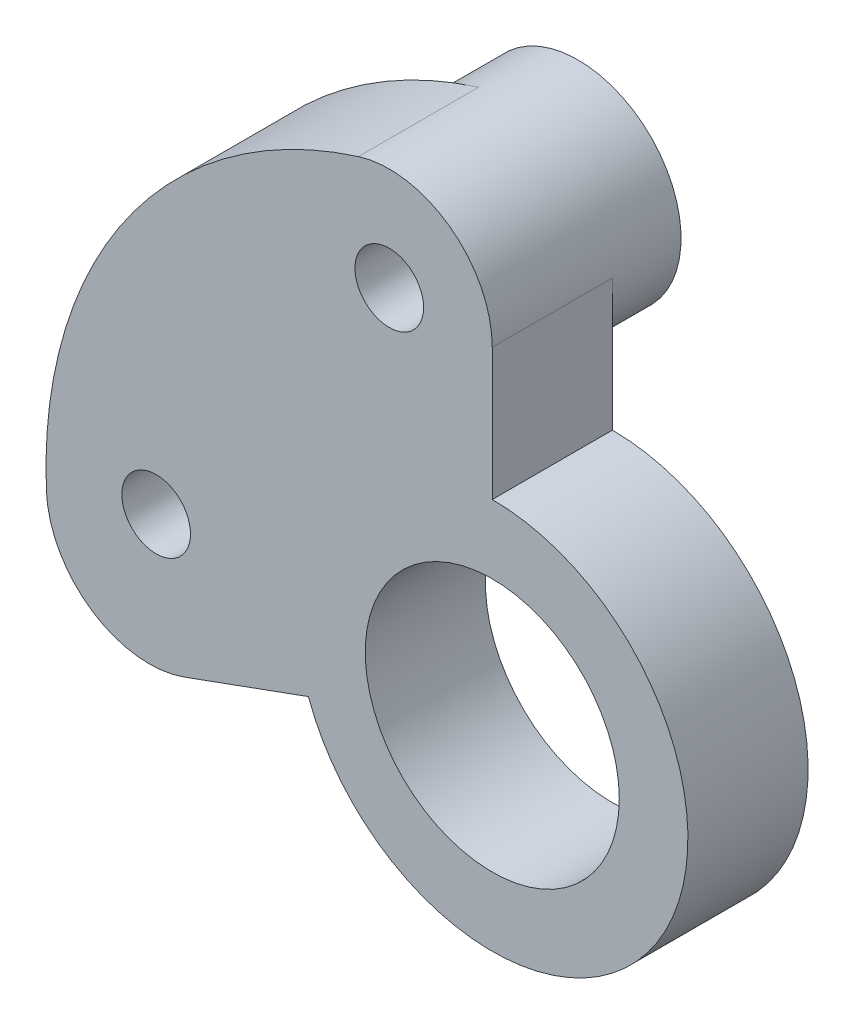
from build123d import *
from build123d.topology import SkipClean

# Parameters (mm, degrees)
SKETCH1_R           = 13
SKETCH1_R_2         = 3.7
BOSS_EXTRUDE1_DEPTH = 3.5
CUT_EXTRUDE1_START  = -10
CUT_EXTRUDE1_DEPTH  = 10
SKETCH3_R           = 1
CUT_EXTRUDE2_DEPTH  = 10
SKETCH5_R           = 1
CUT_EXTRUDE3_DEPTH  = 6
FILLET1_R           = 3
SKETCH6_R           = 3
SKETCH6_R_2         = 1
BOSS_EXTRUDE2_DEPTH = 0.5
SKETCH6_3_R         = 3
SKETCH6_3_R_2       = 1
BOSS_EXTRUDE3_DEPTH = 2


with BuildPart() as part:
    # Sketch1 → Boss-Extrude1 (new body)
    with BuildSketch(Plane.XY):
        Circle(SKETCH1_R)
        Circle(SKETCH1_R_2, mode=Mode.SUBTRACT)
    extrude(amount=BOSS_EXTRUDE1_DEPTH)

    # Sketch2 → Cut-Extrude1 (cut)
    with BuildSketch(Plane.XY.offset(3.5).offset(CUT_EXTRUDE1_START)):
        with BuildLine():
            ThreePointArc((5.7, 0), (0.989794613, -5.613404192), (-5.356247938, -1.949514817))
            Line((-5.356247938, -1.949514817), (-12.21600407, -4.446261863))
            ThreePointArc((-12.21600407, -4.446261863), (2.25742631, -12.802500789), (13, 0))
            ThreePointArc((13, 0), (9.192388155, 9.192388155), (0, 13))
            Line((0, 13), (0, 5.7))
            ThreePointArc((0, 5.7), (4.030508653, 4.030508653), (5.7, 0))
        make_face()
    extrude(amount=CUT_EXTRUDE1_DEPTH, mode=Mode.SUBTRACT)

    # Sketch3 → Cut-Extrude2 (cut)
    with BuildSketch(Plane.XY.offset(3.5)):
        with Locations((-3, 9.539392014)):
            Circle(SKETCH3_R)
    extrude(amount=-CUT_EXTRUDE2_DEPTH, mode=Mode.SUBTRACT)

    # Sketch5 → Cut-Extrude3 (cut)
    with BuildSketch(Plane.XY.offset(3.5)):
        with Locations((-9.790353578, 0.434714634)):
            Circle(SKETCH5_R)
    extrude(amount=-CUT_EXTRUDE3_DEPTH, mode=Mode.SUBTRACT)

    # Fillet1
    fillet1_edges = [part.edges().sort_by_distance(p)[0] for p in [
        (-12.21600407, -4.446261863, 1.75),
        (0, 13, 1.75),
    ]]
    fillet(fillet1_edges, radius=FILLET1_R)

    # Sketch6 → Boss-Extrude2 (add)
    with SkipClean():  # the faces are left unmerged after this step: merging them gives an invalid solid
        with BuildSketch(Plane(origin=(0, 0, 0), x_dir=(-1, 0, 0), z_dir=(0, 0, -1))):
            with Locations((9.790353578, 0.434714634)):
                Circle(SKETCH6_R)
            with Locations((9.790353578, 0.434714634)):
                Circle(SKETCH6_R_2, mode=Mode.SUBTRACT)
        extrude(amount=BOSS_EXTRUDE2_DEPTH)

    # Sketch6_3 → Boss-Extrude3 (add)
    with SkipClean():  # the faces are left unmerged after this step: merging them gives an invalid solid
        with BuildSketch(Plane(origin=(0, 0, 0), x_dir=(-1, 0, 0), z_dir=(0, 0, -1))):
            with Locations((3, 9.539392014)):
                Circle(SKETCH6_3_R)
            with Locations((3, 9.539392014)):
                Circle(SKETCH6_3_R_2, mode=Mode.SUBTRACT)
        extrude(amount=BOSS_EXTRUDE3_DEPTH)


solid = part.part
